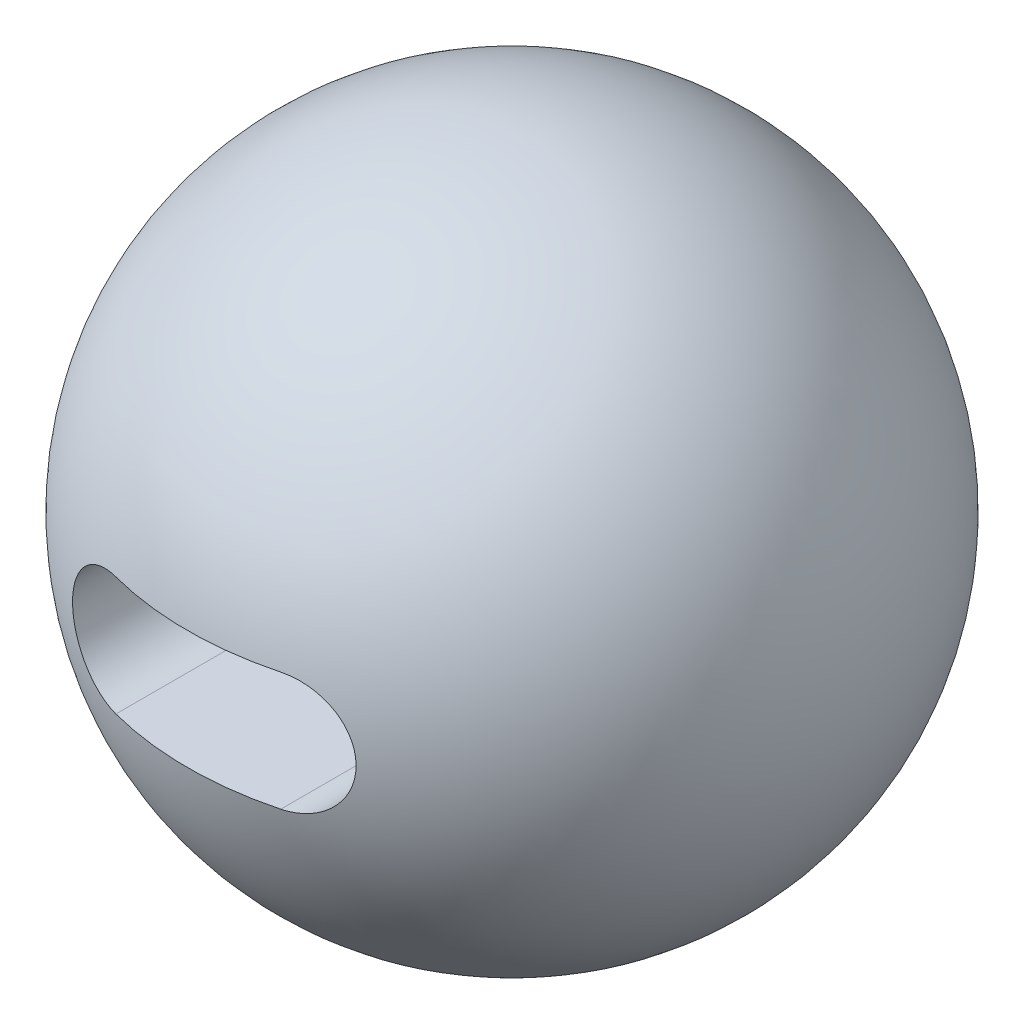
from build123d import *

# Parameters (mm, degrees)
CUT_EXTRUDE2_DEPTH = 500


with BuildPart() as part:
    # Sketch1 → Revolve1 (revolve)
    with BuildSketch(Plane.XY):
        with BuildLine():
            Line((0, -500), (0, 500))
            ThreePointArc((0, 500), (-500, 0), (0, -500))
        make_face()
    revolve(axis=Axis((0, -500, 0), (0, 1, 0)))

    # Sketch7 → Cut-Extrude2 (cut)
    with BuildSketch(Plane.XY.offset(500)):
        with BuildLine():
            Line((-125, 90), (125, 90))
            ThreePointArc((125, 90), (215, 0), (125, -90))
            Line((125, -90), (-125, -90))
            ThreePointArc((-125, -90), (-215, 0), (-125, 90))
        make_face()
    extrude(amount=-CUT_EXTRUDE2_DEPTH, mode=Mode.SUBTRACT)


solid = part.part
